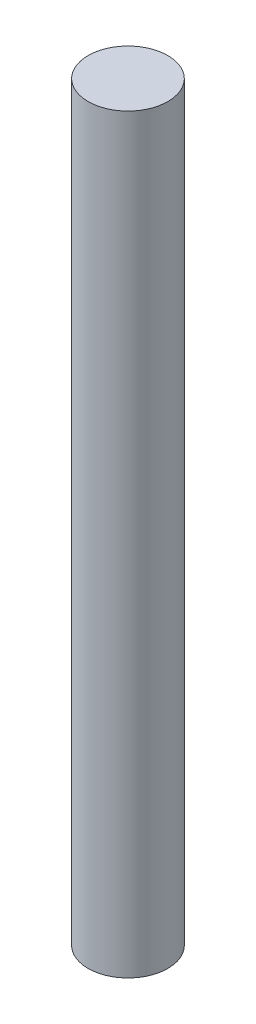
from build123d import *

# Parameters (mm, degrees)
SKETCH1_R           = 0.75
BOSS_EXTRUDE1_DEPTH = 14.125


with BuildPart() as part:
    # Sketch1 → Boss-Extrude1 (new body)
    with BuildSketch(Plane(origin=(0, 0, 0), x_dir=(1, 0, 0), z_dir=(0, 1, 0))):
        Circle(SKETCH1_R)
    extrude(amount=BOSS_EXTRUDE1_DEPTH)


solid = part.part
